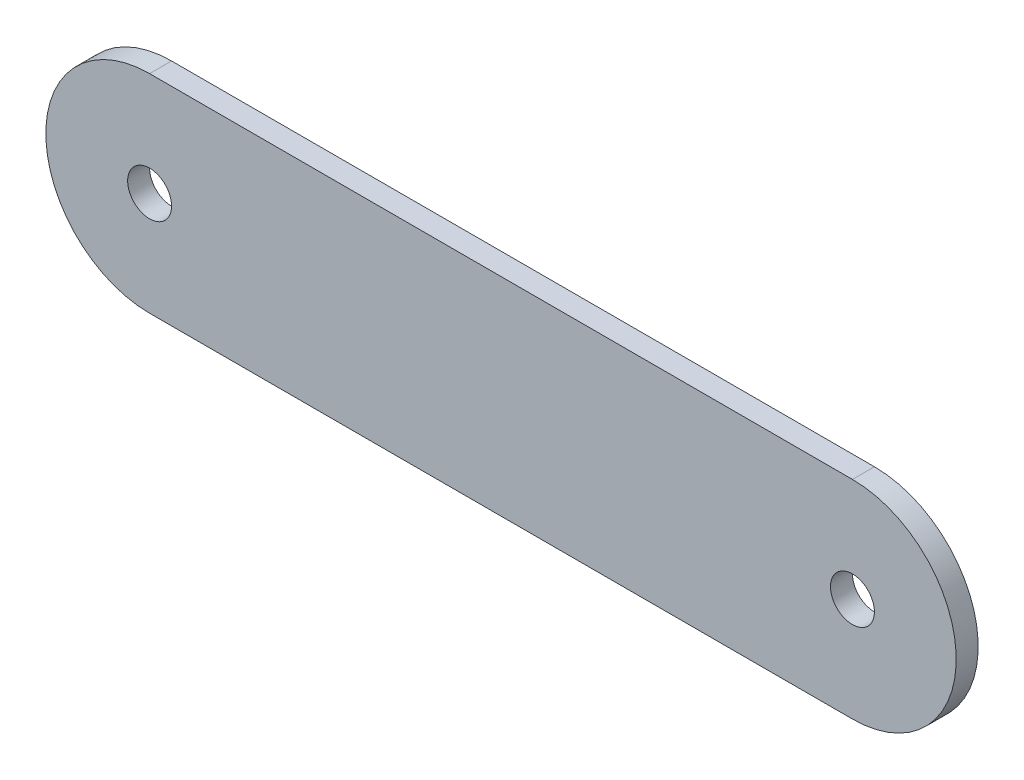
from build123d import *

# Parameters (mm, degrees)
SKETCH1_R           = 6.35
BOSS_EXTRUDE1_DEPTH = 3.175


with BuildPart() as part:
    # Sketch1 → Boss-Extrude1 (new body, symmetric)
    with BuildSketch(Plane.XY):
        with BuildLine():
            Line((-101.6, 30), (101.6, 30))
            ThreePointArc((101.6, 30), (131.6, 0), (101.6, -30))
            Line((101.6, -30), (-101.6, -30))
            ThreePointArc((-101.6, -30), (-131.6, 0), (-101.6, 30))
        make_face()
        with Locations((-101.6, 0)):
            Circle(SKETCH1_R, mode=Mode.SUBTRACT)
        with Locations((101.6, 0)):
            Circle(SKETCH1_R, mode=Mode.SUBTRACT)
    extrude(amount=BOSS_EXTRUDE1_DEPTH, both=True)


solid = part.part
